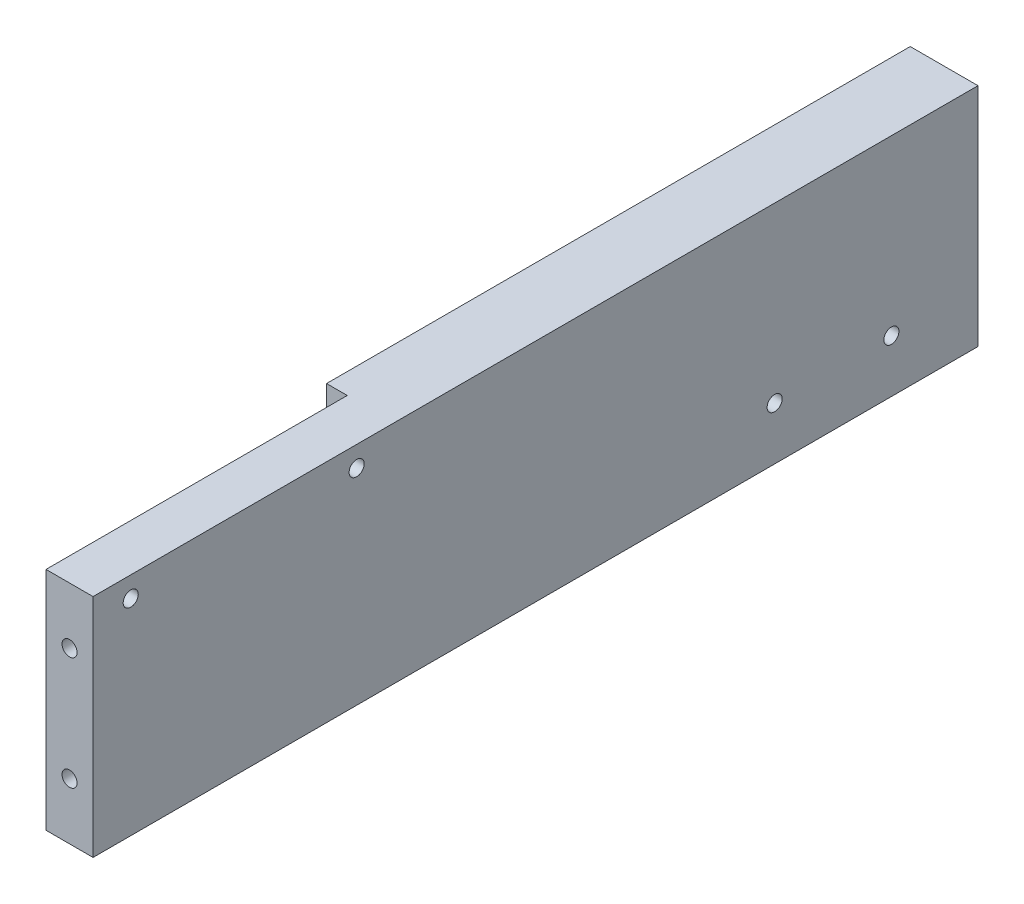
from build123d import *

# Parameters (mm, degrees)
ESQUISSE1_W             = 155
ESQUISSE1_H             = 60
ESQUISSE1_R             = 2
BOSS_EXTRU_1_DEPTH      = 18
ESQUISSE1_5_W           = 80
ESQUISSE1_5_H           = 60
ESQUISSE1_5_R           = 2
BOSS_EXTRU_2_DEPTH      = 12.5
ESQUISSE6_R             = 2
ENL_V_MAT_EXTRU_2_DEPTH = 10


with BuildPart() as part:
    # Esquisse1 → Boss.-Extru.1 (new body)
    with BuildSketch(Plane(origin=(0, 0, 0), x_dir=(0, 0, -1), z_dir=(1, 0, 0))):
        with Locations((92.673222626, -22)):
            Rectangle(ESQUISSE1_W, ESQUISSE1_H)
        with Locations((116.173222626, -38)):
            Circle(ESQUISSE1_R, mode=Mode.SUBTRACT)
        with Locations((147.173222626, -38)):
            Circle(ESQUISSE1_R, mode=Mode.SUBTRACT)
    extrude(amount=-BOSS_EXTRU_1_DEPTH)

    # Esquisse1_5 → Boss.-Extru.2 (add)
    with BuildSketch(Plane(origin=(0, 0, 0), x_dir=(0, 0, -1), z_dir=(1, 0, 0))):
        with Locations((-24.826777374, -22)):
            Rectangle(ESQUISSE1_5_W, ESQUISSE1_5_H)
        with Locations((-54.826777374, 2.55)):
            Circle(ESQUISSE1_5_R, mode=Mode.SUBTRACT)
        with Locations((5.173222626, 2.55)):
            Circle(ESQUISSE1_5_R, mode=Mode.SUBTRACT)
    extrude(amount=-BOSS_EXTRU_2_DEPTH)

    # Esquisse6 → Enlèv. mat.-Extru.2 (cut)
    with BuildSketch(Plane.XY.offset(64.826777374)):
        with Locations((-6.25, -7)):
            Circle(ESQUISSE6_R)
        with Locations((-6.25, -37)):
            Circle(ESQUISSE6_R)
    extrude(amount=-ENL_V_MAT_EXTRU_2_DEPTH, mode=Mode.SUBTRACT)


solid = part.part
